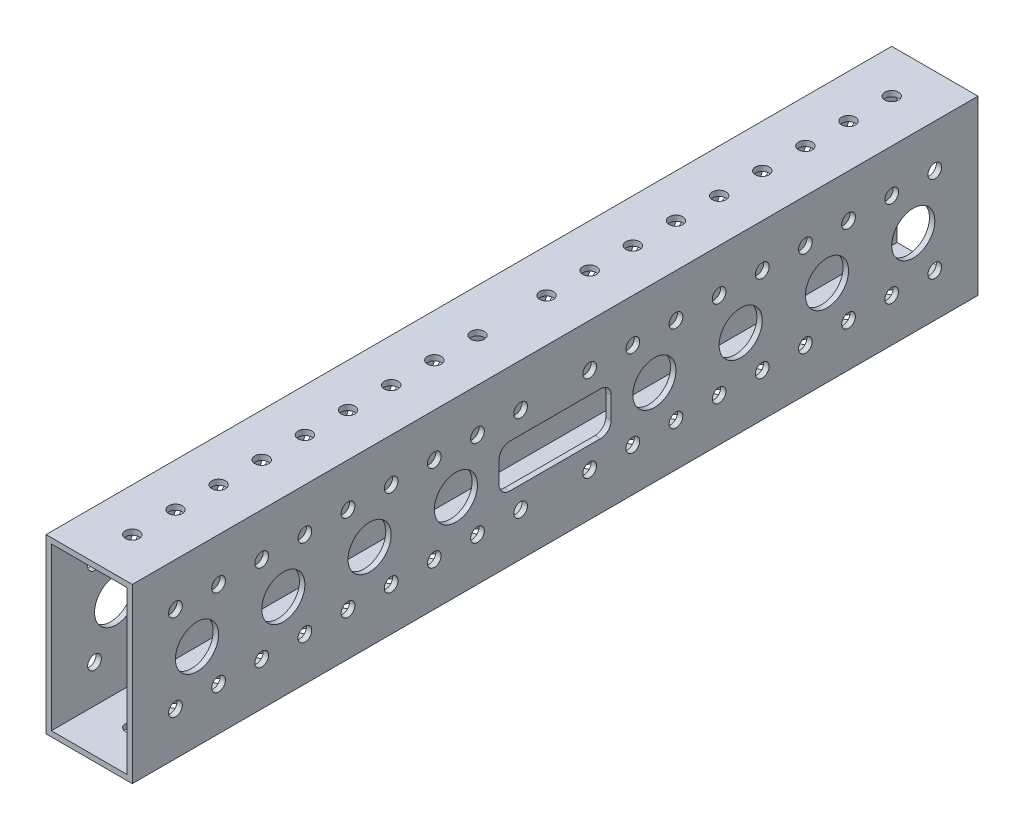
from build123d import *

# Parameters (mm, degrees)
SKETCH1_W                   = 25.4
SKETCH1_H                   = 50.8
BOSS_EXTRUDE1_DEPTH         = 248.92
SHELL1_T                    = -1.5875
F_21_0_159_DIAMETER_HOLE1_D = 4.0386
LPATTERN1_COUNT             = 9
LPATTERN1_PITCH             = 12.7
F_21_0_159_DIAMETER_HOLE2_D = 4.0386
LPATTERN2_COUNT             = 9
LPATTERN2_PITCH             = 12.7
LPATTERN2_COUNT_DIR2        = 2
LPATTERN2_PITCH_DIR2        = 25.4
F_1_2_0_5_DIAMETER_HOLE1_D  = 12.7
LPATTERN3_COUNT             = 4
LPATTERN3_PITCH             = 25.4
MIRROR1_COPY_1_D            = 12.7
MIRROR1_COPY_2_D            = 12.7
MIRROR1_COPY_3_D            = 12.7
MIRROR1_COPY_4_D            = 4.0386
MIRROR1_COPY_5_D            = 4.0386
MIRROR1_COPY_6_D            = 4.0386
MIRROR1_COPY_7_D            = 4.0386
MIRROR1_COPY_8_D            = 4.0386
MIRROR1_COPY_9_D            = 4.0386
MIRROR1_COPY_10_D           = 4.0386
MIRROR1_COPY_11_D           = 4.0386
MIRROR1_COPY_12_D           = 4.0386
MIRROR1_COPY_13_D           = 4.0386
MIRROR1_COPY_14_D           = 4.0386
MIRROR1_COPY_15_D           = 4.0386
MIRROR1_COPY_16_D           = 4.0386
MIRROR1_COPY_17_D           = 4.0386
MIRROR1_COPY_18_D           = 4.0386
MIRROR1_COPY_19_D           = 4.0386
MIRROR1_COPY_20_D           = 4.0386
MIRROR1_COPY_21_D           = 4.0386
MIRROR1_COPY_22_D           = 4.0386
MIRROR1_COPY_23_D           = 4.0386
MIRROR1_COPY_24_D           = 4.0386
MIRROR1_COPY_25_D           = 4.0386
MIRROR1_COPY_26_D           = 4.0386
MIRROR1_COPY_27_D           = 4.0386
MIRROR1_COPY_28_D           = 4.0386
SKETCH9_W                   = 33.02
SKETCH9_H                   = 12.7
CUT_EXTRUDE1_DEPTH          = 1
CUT_EXTRUDE1_DEPTH_BACK     = 26.4
FILLET1_R                   = 3.175


with BuildPart() as part:
    # Sketch1 → Boss-Extrude1 (new body)
    with BuildSketch(Plane.XY):
        with Locations((12.7, 25.4)):
            Rectangle(SKETCH1_W, SKETCH1_H)
    extrude(amount=BOSS_EXTRUDE1_DEPTH)

    # Shell1
    shell1_openings = [part.faces().sort_by_distance(p)[0] for p in [
        (12.7, 25.4, 248.92),
        (12.7, 25.4, 0),
    ]]
    offset(amount=SHELL1_T, openings=shell1_openings, kind=Kind.INTERSECTION)

    # #21 (0.159) Diameter Hole1 (through all)
    with Locations(Plane(origin=(0, 50.8, 0), x_dir=(1, 0, 0), z_dir=(0, 1, 0))):
        with Locations((12.7, -236.22)):
            f_21_0_159_diameter_hole1 = Hole(F_21_0_159_DIAMETER_HOLE1_D / 2)

    # LPattern1: #21 (0.159) Diameter Hole1 ×9
    with Locations(*[(0, 0, -i * LPATTERN1_PITCH) for i in range(1, LPATTERN1_COUNT)]):
        add(f_21_0_159_diameter_hole1, mode=Mode.SUBTRACT)

    # #21 (0.159) Diameter Hole2 (through all)
    with Locations(Plane(origin=(25.4, 0, 0), x_dir=(0, 0, -1), z_dir=(1, 0, 0))):
        with Locations((-236.22, 38.1)):
            f_21_0_159_diameter_hole2 = Hole(F_21_0_159_DIAMETER_HOLE2_D / 2)

    # LPattern2: 21 _0.159_ Diameter Hole2 9 × 2
    with Locations(*[(0, -j * LPATTERN2_PITCH_DIR2, -i * LPATTERN2_PITCH) for i in range(LPATTERN2_COUNT) for j in range(LPATTERN2_COUNT_DIR2) if (i, j) != (0, 0)]):
        add(f_21_0_159_diameter_hole2, mode=Mode.SUBTRACT)

    # 1/2 (0.5) Diameter Hole1 (through all)
    with Locations(Plane(origin=(25.4, 0, 0), x_dir=(0, 0, -1), z_dir=(1, 0, 0))):
        with Locations((-229.87, 25.4)):
            f_1_2_0_5_diameter_hole1 = Hole(F_1_2_0_5_DIAMETER_HOLE1_D / 2)

    # LPattern3: 1/2 (0.5) Diameter Hole1 ×4
    with Locations(*[(0, 0, -i * LPATTERN3_PITCH) for i in range(1, LPATTERN3_COUNT)]):
        add(f_1_2_0_5_diameter_hole1, mode=Mode.SUBTRACT)

    # Mirror1: 1/2 (0.5) Diameter Hole1, #21 (0.159) Diameter Hole2, #21 (0.159) Diameter Hole1 across plane
    add(f_1_2_0_5_diameter_hole1.mirror(Plane.XY.offset(124.46)), mode=Mode.SUBTRACT)
    add(f_21_0_159_diameter_hole2.mirror(Plane.XY.offset(124.46)), mode=Mode.SUBTRACT)
    add(f_21_0_159_diameter_hole1.mirror(Plane.XY.offset(124.46)), mode=Mode.SUBTRACT)

    # Mirror1 copy 1 (through all)
    with Locations(Plane(origin=(25.4, 0, 274.32), x_dir=(0, 0, 1), z_dir=(1, 0, 0))):
        with Locations((-229.87, -25.4)):
            Hole(MIRROR1_COPY_1_D / 2)

    # Mirror1 copy 2 (through all)
    with Locations(Plane(origin=(25.4, 0, 299.72), x_dir=(0, 0, 1), z_dir=(1, 0, 0))):
        with Locations((-229.87, -25.4)):
            Hole(MIRROR1_COPY_2_D / 2)

    # Mirror1 copy 3 (through all)
    with Locations(Plane(origin=(25.4, 0, 325.12), x_dir=(0, 0, 1), z_dir=(1, 0, 0))):
        with Locations((-229.87, -25.4)):
            Hole(MIRROR1_COPY_3_D / 2)

    # Mirror1 copy 4 (through all)
    with Locations(Plane(origin=(25.4, -25.4, 248.92), x_dir=(0, 0, 1), z_dir=(1, 0, 0))):
        with Locations((-236.22, -38.1)):
            Hole(MIRROR1_COPY_4_D / 2)

    # Mirror1 copy 5 (through all)
    with Locations(Plane(origin=(25.4, 0, 261.62), x_dir=(0, 0, 1), z_dir=(1, 0, 0))):
        with Locations((-236.22, -38.1)):
            Hole(MIRROR1_COPY_5_D / 2)

    # Mirror1 copy 6 (through all)
    with Locations(Plane(origin=(25.4, -25.4, 261.62), x_dir=(0, 0, 1), z_dir=(1, 0, 0))):
        with Locations((-236.22, -38.1)):
            Hole(MIRROR1_COPY_6_D / 2)

    # Mirror1 copy 7 (through all)
    with Locations(Plane(origin=(25.4, 0, 274.32), x_dir=(0, 0, 1), z_dir=(1, 0, 0))):
        with Locations((-236.22, -38.1)):
            Hole(MIRROR1_COPY_7_D / 2)

    # Mirror1 copy 8 (through all)
    with Locations(Plane(origin=(25.4, -25.4, 274.32), x_dir=(0, 0, 1), z_dir=(1, 0, 0))):
        with Locations((-236.22, -38.1)):
            Hole(MIRROR1_COPY_8_D / 2)

    # Mirror1 copy 9 (through all)
    with Locations(Plane(origin=(25.4, 0, 287.02), x_dir=(0, 0, 1), z_dir=(1, 0, 0))):
        with Locations((-236.22, -38.1)):
            Hole(MIRROR1_COPY_9_D / 2)

    # Mirror1 copy 10 (through all)
    with Locations(Plane(origin=(25.4, -25.4, 287.02), x_dir=(0, 0, 1), z_dir=(1, 0, 0))):
        with Locations((-236.22, -38.1)):
            Hole(MIRROR1_COPY_10_D / 2)

    # Mirror1 copy 11 (through all)
    with Locations(Plane(origin=(25.4, 0, 299.72), x_dir=(0, 0, 1), z_dir=(1, 0, 0))):
        with Locations((-236.22, -38.1)):
            Hole(MIRROR1_COPY_11_D / 2)

    # Mirror1 copy 12 (through all)
    with Locations(Plane(origin=(25.4, -25.4, 299.72), x_dir=(0, 0, 1), z_dir=(1, 0, 0))):
        with Locations((-236.22, -38.1)):
            Hole(MIRROR1_COPY_12_D / 2)

    # Mirror1 copy 13 (through all)
    with Locations(Plane(origin=(25.4, 0, 312.42), x_dir=(0, 0, 1), z_dir=(1, 0, 0))):
        with Locations((-236.22, -38.1)):
            Hole(MIRROR1_COPY_13_D / 2)

    # Mirror1 copy 14 (through all)
    with Locations(Plane(origin=(25.4, -25.4, 312.42), x_dir=(0, 0, 1), z_dir=(1, 0, 0))):
        with Locations((-236.22, -38.1)):
            Hole(MIRROR1_COPY_14_D / 2)

    # Mirror1 copy 15 (through all)
    with Locations(Plane(origin=(25.4, 0, 325.12), x_dir=(0, 0, 1), z_dir=(1, 0, 0))):
        with Locations((-236.22, -38.1)):
            Hole(MIRROR1_COPY_15_D / 2)

    # Mirror1 copy 16 (through all)
    with Locations(Plane(origin=(25.4, -25.4, 325.12), x_dir=(0, 0, 1), z_dir=(1, 0, 0))):
        with Locations((-236.22, -38.1)):
            Hole(MIRROR1_COPY_16_D / 2)

    # Mirror1 copy 17 (through all)
    with Locations(Plane(origin=(25.4, 0, 337.82), x_dir=(0, 0, 1), z_dir=(1, 0, 0))):
        with Locations((-236.22, -38.1)):
            Hole(MIRROR1_COPY_17_D / 2)

    # Mirror1 copy 18 (through all)
    with Locations(Plane(origin=(25.4, -25.4, 337.82), x_dir=(0, 0, 1), z_dir=(1, 0, 0))):
        with Locations((-236.22, -38.1)):
            Hole(MIRROR1_COPY_18_D / 2)

    # Mirror1 copy 19 (through all)
    with Locations(Plane(origin=(25.4, 0, 350.52), x_dir=(0, 0, 1), z_dir=(1, 0, 0))):
        with Locations((-236.22, -38.1)):
            Hole(MIRROR1_COPY_19_D / 2)

    # Mirror1 copy 20 (through all)
    with Locations(Plane(origin=(25.4, -25.4, 350.52), x_dir=(0, 0, 1), z_dir=(1, 0, 0))):
        with Locations((-236.22, -38.1)):
            Hole(MIRROR1_COPY_20_D / 2)

    # Mirror1 copy 21 (through all)
    with Locations(Plane(origin=(0, 50.8, 261.62), x_dir=(1, 0, 0), z_dir=(0, 1, 0))):
        with Locations((12.7, 236.22)):
            Hole(MIRROR1_COPY_21_D / 2)

    # Mirror1 copy 22 (through all)
    with Locations(Plane(origin=(0, 50.8, 274.32), x_dir=(1, 0, 0), z_dir=(0, 1, 0))):
        with Locations((12.7, 236.22)):
            Hole(MIRROR1_COPY_22_D / 2)

    # Mirror1 copy 23 (through all)
    with Locations(Plane(origin=(0, 50.8, 287.02), x_dir=(1, 0, 0), z_dir=(0, 1, 0))):
        with Locations((12.7, 236.22)):
            Hole(MIRROR1_COPY_23_D / 2)

    # Mirror1 copy 24 (through all)
    with Locations(Plane(origin=(0, 50.8, 299.72), x_dir=(1, 0, 0), z_dir=(0, 1, 0))):
        with Locations((12.7, 236.22)):
            Hole(MIRROR1_COPY_24_D / 2)

    # Mirror1 copy 25 (through all)
    with Locations(Plane(origin=(0, 50.8, 312.42), x_dir=(1, 0, 0), z_dir=(0, 1, 0))):
        with Locations((12.7, 236.22)):
            Hole(MIRROR1_COPY_25_D / 2)

    # Mirror1 copy 26 (through all)
    with Locations(Plane(origin=(0, 50.8, 325.12), x_dir=(1, 0, 0), z_dir=(0, 1, 0))):
        with Locations((12.7, 236.22)):
            Hole(MIRROR1_COPY_26_D / 2)

    # Mirror1 copy 27 (through all)
    with Locations(Plane(origin=(0, 50.8, 337.82), x_dir=(1, 0, 0), z_dir=(0, 1, 0))):
        with Locations((12.7, 236.22)):
            Hole(MIRROR1_COPY_27_D / 2)

    # Mirror1 copy 28 (through all)
    with Locations(Plane(origin=(0, 50.8, 350.52), x_dir=(1, 0, 0), z_dir=(0, 1, 0))):
        with Locations((12.7, 236.22)):
            Hole(MIRROR1_COPY_28_D / 2)

    # Sketch9 → Cut-Extrude1 (cut, two sides)
    with BuildSketch(Plane(origin=(25.4, 0, 0), x_dir=(0, 0, -1), z_dir=(1, 0, 0))) as cut_extrude1_sk:
        with Locations((-124.46, 25.4)):
            Rectangle(SKETCH9_W, SKETCH9_H)
    extrude(amount=CUT_EXTRUDE1_DEPTH, mode=Mode.SUBTRACT)
    extrude(cut_extrude1_sk.sketch, amount=-CUT_EXTRUDE1_DEPTH_BACK, mode=Mode.SUBTRACT)

    # Fillet1
    fillet1_edges = [part.edges().sort_by_distance(p)[0] for p in [
        (24.60625, 19.05, 140.97),
        (0.79375, 19.05, 140.97),
        (24.60625, 31.75, 140.97),
        (0.79375, 31.75, 140.97),
        (24.60625, 31.75, 107.95),
        (0.79375, 31.75, 107.95),
        (24.60625, 19.05, 107.95),
        (0.79375, 19.05, 107.95),
    ]]
    fillet(fillet1_edges, radius=FILLET1_R)


solid = part.part
